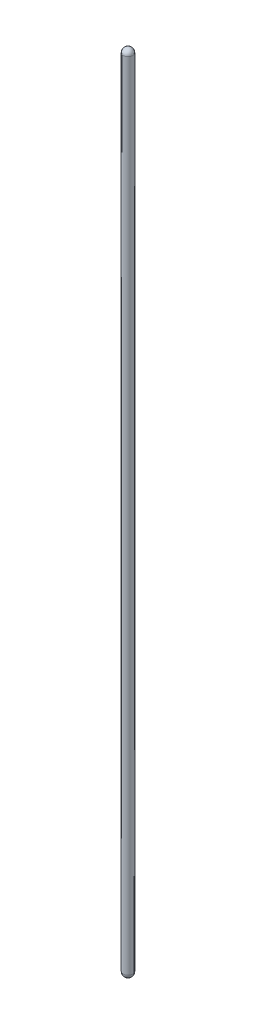
from build123d import *

# Parameters (mm, degrees)
IZIM2_R                     = 0.5
Y_KSEKLIK_EKSTR_ZYON1_DEPTH = 84
RADYUS1_R                   = 0.5
RADYUS4_R                   = 0.5


with BuildPart() as part:
    # Çizim2 → Yükseklik-Ekstrüzyon1 (new body)
    with BuildSketch(Plane(origin=(0, 0, 0), x_dir=(1, 0, 0), z_dir=(0, 1, 0))):
        Circle(IZIM2_R)
    extrude(amount=Y_KSEKLIK_EKSTR_ZYON1_DEPTH)

    # Radyus1
    radyus1_edges = [part.edges().sort_by_distance(p)[0] for p in [
        (-0.5, 84, 0),
    ]]
    fillet(radyus1_edges, radius=RADYUS1_R)

    # Radyus4
    radyus4_edges = [part.edges().sort_by_distance(p)[0] for p in [
        (-0.5, 0, 0),
    ]]
    fillet(radyus4_edges, radius=RADYUS4_R)


solid = part.part
